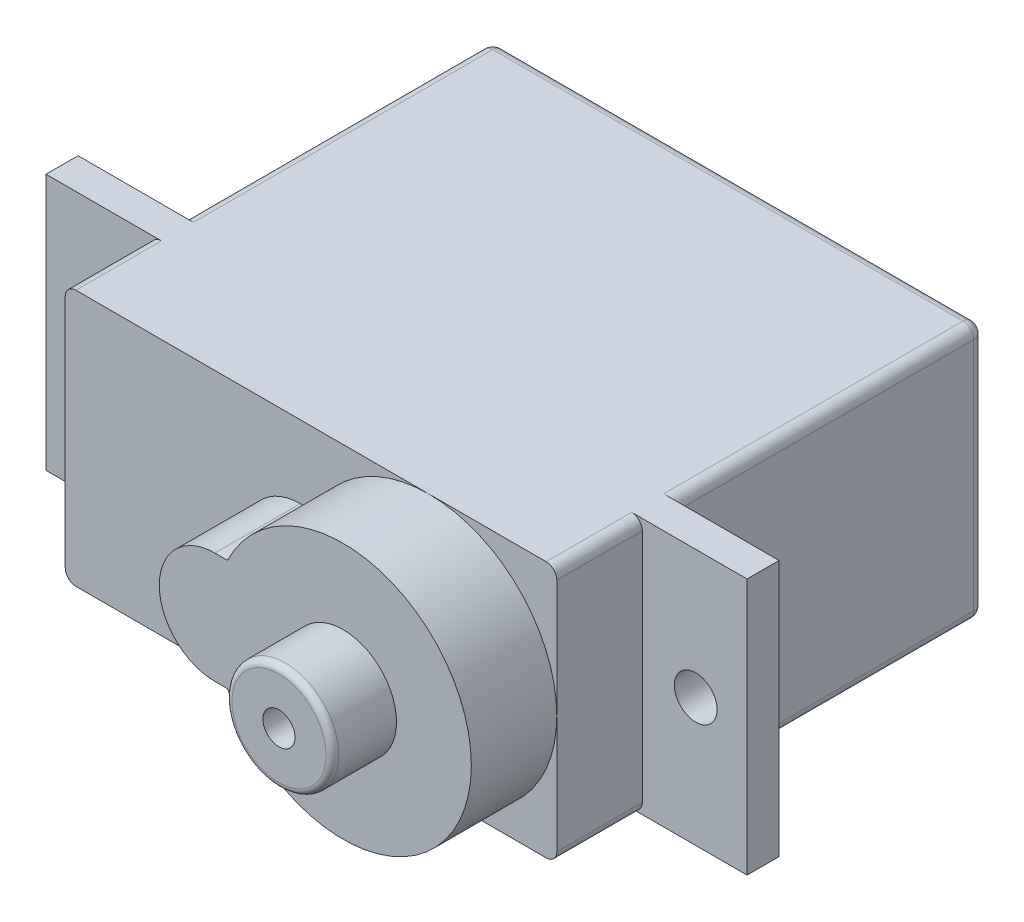
from build123d import *

# Parameters (mm, degrees)
SKETCH_1_W          = 32.8
SKETCH_1_H          = 12
EXTRUDE_1_DEPTH     = 1.5
SKETCH_2_W          = 23
SKETCH_2_H          = 12
EXTRUDE_2_DEPTH     = 4
SKETCH_6_W          = 23
SKETCH_6_H          = 12
EXTRUDE_5_DEPTH     = 14.5
SKETCH_7_R          = 1
CUT_EXTRUDE_2_DEPTH = 2
EXTRUDE_6_DEPTH     = 4
SKETCH_8_R          = 2.5
EXTRUDE_7_DEPTH     = 3
FILLET_1_R          = 0.3
SKETCH_9_R          = 0.75
CUT_EXTRUDE_3_DEPTH = 5
FILLET_2_R          = 0.5


with BuildPart() as part:
    # 草图1 → 凸台-拉伸1 (new body)
    with BuildSketch(Plane.XY):
        Rectangle(SKETCH_1_W, SKETCH_1_H)
    extrude(amount=EXTRUDE_1_DEPTH)

    # 草图2 → 凸台-拉伸2 (add)
    with BuildSketch(Plane.XY.offset(1.5)):
        Rectangle(SKETCH_2_W, SKETCH_2_H)
    extrude(amount=EXTRUDE_2_DEPTH)

    # 草图6 → 凸台-拉伸5 (add)
    with BuildSketch(Plane(origin=(0, 0, 0), x_dir=(-1, 0, 0), z_dir=(0, 0, -1))):
        Rectangle(SKETCH_6_W, SKETCH_6_H)
    extrude(amount=EXTRUDE_5_DEPTH)

    # 草图7 → 切除-拉伸2 (cut)
    with BuildSketch(Plane.XY.offset(1.5)):
        with Locations((-14, 0)):
            Circle(SKETCH_7_R)
        with Locations((14, 0)):
            Circle(SKETCH_7_R)
    extrude(amount=-CUT_EXTRUDE_2_DEPTH, mode=Mode.SUBTRACT)

    # 草图3 → 凸台-拉伸6 (add)
    with BuildSketch(Plane.XY.offset(5.5)):
        with BuildLine():
            Line((-0.5, 2.6), (0.092597666, 2.6))
            ThreePointArc((0.092597666, 2.6), (11.5, 0), (0.092597666, -2.6))
            Line((0.092597666, -2.6), (-0.5, -2.6))
            ThreePointArc((-0.5, -2.6), (-3.1, 0), (-0.5, 2.6))
        make_face()
    extrude(amount=EXTRUDE_6_DEPTH)

    # 草图8 → 凸台-拉伸7 (add)
    with BuildSketch(Plane.XY.offset(9.5)):
        with Locations((5.5, 0)):
            Circle(SKETCH_8_R)
    extrude(amount=EXTRUDE_7_DEPTH)

    # 圆角1
    fillet_1_edges = [part.edges().sort_by_distance(p)[0] for p in [
        (3, 0, 12.5),
    ]]
    fillet(fillet_1_edges, radius=FILLET_1_R)

    # 草图9 → 切除-拉伸3 (cut)
    with BuildSketch(Plane.XY.offset(12.5)):
        with Locations((5.5, 0)):
            Circle(SKETCH_9_R)
    extrude(amount=-CUT_EXTRUDE_3_DEPTH, mode=Mode.SUBTRACT)

    # 圆角2
    fillet_2_edges = [part.edges().sort_by_distance(p)[0] for p in [
        (0, -6, -14.5),
        (-11.5, 0, -14.5),
        (0, 6, -14.5),
        (11.5, 0, -14.5),
        (11.5, -6, 3.5),
        (11.5, -6, -7.25),
        (11.5, 6, -7.25),
        (-11.5, -6, -7.25),
        (-11.5, 6, -7.25),
        (11.5, 6, 3.5),
        (-11.5, -6, 3.5),
        (-11.5, 6, 3.5),
    ]]
    fillet(fillet_2_edges, radius=FILLET_2_R)


solid = part.part
